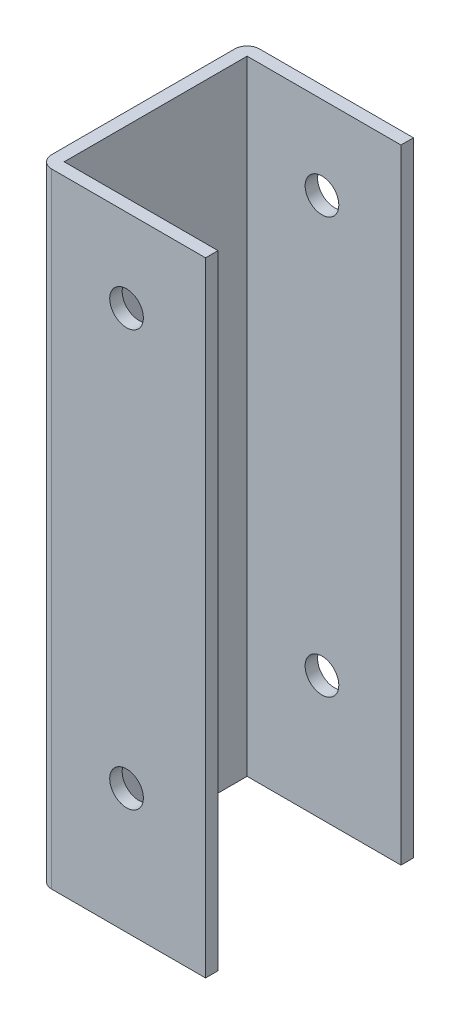
from build123d import *

# Parameters (mm, degrees)
SKETCH_1_W          = 74
SKETCH_1_H          = 44
EXTRUDE_1_DEPTH     = 150
SKETCH_2_W          = 41.146480438
SKETCH_2_H          = 58.393385187
CUT_EXTRUDE_1_DEPTH = 151
SKETCH_3_R          = 4.05
CUT_EXTRUDE_2_DEPTH = 51


with BuildPart() as part:
    # Эскиз1 → Вытянуть-Тонкостенный1 (new body)
    with BuildSketch(Plane(origin=(0, 0, 0), x_dir=(1, 0, 0), z_dir=(0, 1, 0))):
        with BuildLine():
            Line((40, 22), (40, -22))
            ThreePointArc((40, -22), (39.121320344, -24.121320344), (37, -25))
            Line((37, -25), (-37, -25))
            ThreePointArc((-37, -25), (-39.121320344, -24.121320344), (-40, -22))
            Line((-40, -22), (-40, 22))
            ThreePointArc((-40, 22), (-39.121320344, 24.121320344), (-37, 25))
            Line((-37, 25), (37, 25))
            ThreePointArc((37, 25), (39.121320344, 24.121320344), (40, 22))
        make_face()
        Rectangle(SKETCH_1_W, SKETCH_1_H, mode=Mode.SUBTRACT)
    extrude(amount=EXTRUDE_1_DEPTH)

    # Эскиз2 → Вырез-Вытянуть1 (cut, through all)
    with BuildSketch(Plane(origin=(0, 150, 0), x_dir=(1, 0, 0), z_dir=(0, 1, 0))):
        with Locations((20.573240219, 1.776081122)):
            Rectangle(SKETCH_2_W, SKETCH_2_H)
    extrude(amount=-CUT_EXTRUDE_1_DEPTH, mode=Mode.SUBTRACT)

    # Эскиз3 → Вырез-Вытянуть2 (cut, through all)
    with BuildSketch(Plane(origin=(0, 0, -25), x_dir=(-1, 0, 0), z_dir=(0, 0, -1))):
        with Locations((19, 130)):
            Circle(SKETCH_3_R)
        with Locations((19, 30)):
            Circle(SKETCH_3_R)
    extrude(amount=-CUT_EXTRUDE_2_DEPTH, mode=Mode.SUBTRACT)


solid = part.part
